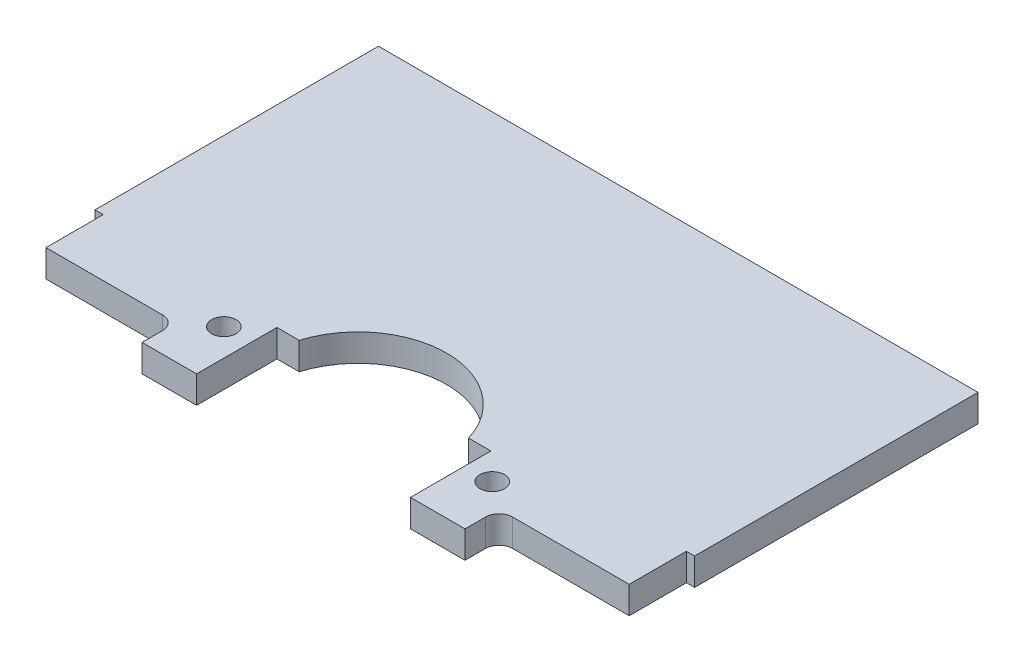
from build123d import *

# Parameters (mm, degrees)
SKETCH1_R           = 1.143
SKETCH1_W           = 5.08
SKETCH1_H           = 3.175
BOSS_EXTRUDE1_DEPTH = 2.54
FILLET1_R           = 1.27


with BuildPart() as part:
    # Sketch1 → Boss-Extrude1 (new body)
    with BuildSketch(Plane(origin=(0, 0, 0), x_dir=(1, 0, 0), z_dir=(0, 1, 0))):
        with BuildLine():
            Line((-27.94, 13.208), (-27.94, -13.208))
            Line((-27.94, -13.208), (-27.178, -13.208))
            Line((-27.178, -13.208), (-7.509126714, -13.208))
            ThreePointArc((-7.509126714, -13.208), (0, -8.382), (7.509126714, -13.208))
            Line((7.509126714, -13.208), (27.178, -13.208))
            Line((27.178, -13.208), (27.94, -13.208))
            Line((27.94, -13.208), (27.94, 13.208))
            Line((27.94, 13.208), (-27.94, 13.208))
        make_face()
        with BuildLine():
            Line((-7.509126714, -13.208), (-27.178, -13.208))
            Line((-27.178, -13.208), (-27.178, -18.542))
            Line((-27.178, -18.542), (-15.0495, -18.542))
            Line((-15.0495, -18.542), (-9.9695, -18.542))
            Line((-9.9695, -18.542), (-9.9695, -14.224))
            Line((-9.9695, -14.224), (-7.894457296, -14.224))
            ThreePointArc((-7.894457296, -14.224), (-7.718527326, -13.709652922), (-7.509126714, -13.208))
        make_face()
        with Locations((-12.5095, -16.637)):
            Circle(SKETCH1_R, mode=Mode.SUBTRACT)
        with BuildLine():
            Line((27.178, -13.208), (7.509126714, -13.208))
            ThreePointArc((7.509126714, -13.208), (7.718527326, -13.709652922), (7.894457296, -14.224))
            Line((7.894457296, -14.224), (9.9695, -14.224))
            Line((9.9695, -14.224), (9.9695, -18.542))
            Line((9.9695, -18.542), (15.0495, -18.542))
            Line((15.0495, -18.542), (27.178, -18.542))
            Line((27.178, -18.542), (27.178, -13.208))
        make_face()
        with Locations((12.5095, -16.637)):
            Circle(SKETCH1_R, mode=Mode.SUBTRACT)
        with Locations((-12.5095, -20.1295)):
            Rectangle(SKETCH1_W, SKETCH1_H)
        with Locations((12.5095, -20.1295)):
            Rectangle(SKETCH1_W, SKETCH1_H)
    extrude(amount=BOSS_EXTRUDE1_DEPTH)

    # Fillet1
    fillet1_edges = [part.edges().sort_by_distance(p)[0] for p in [
        (15.0495, 1.27, 18.542),
        (-15.0495, 1.27, 18.542),
    ]]
    fillet(fillet1_edges, radius=FILLET1_R)


solid = part.part
